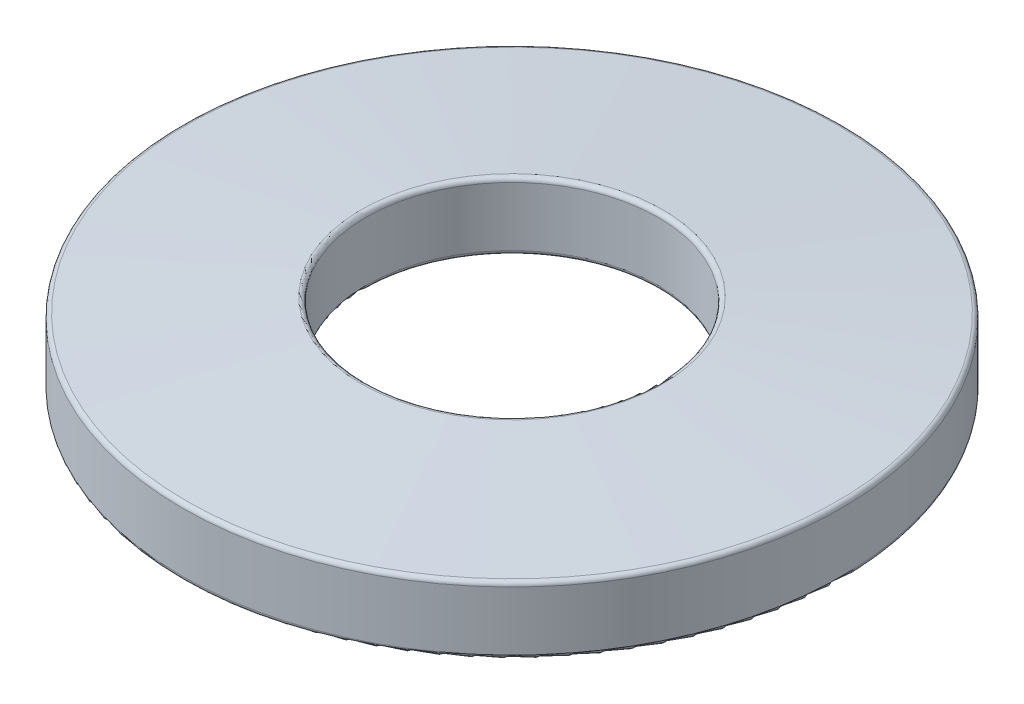
from build123d import *

# Parameters (mm, degrees)
FILLET1_R = 0.254


with BuildPart() as part:
    # Sketch2 → Revolve1 (revolve)
    with BuildSketch(Plane(origin=(0, 0, 0), x_dir=(0, 0, -1), z_dir=(1, 0, 0))):
        Polygon((8.5598, 4.826), (8.5598, 0.8636), (19.304, 0), (19.304, 3.9624), align=None)
    revolve(axis=Axis((0, 0, 0), (0, 1, 0)))

    # Fillet1
    fillet1_edges = [part.edges().sort_by_distance(p)[0] for p in [
        (0, 3.9624, 19.304),
        (0, 0, 19.304),
        (0, 0.8636, 8.5598),
        (0, 4.826, 8.5598),
    ]]
    fillet(fillet1_edges, radius=FILLET1_R)


solid = part.part
